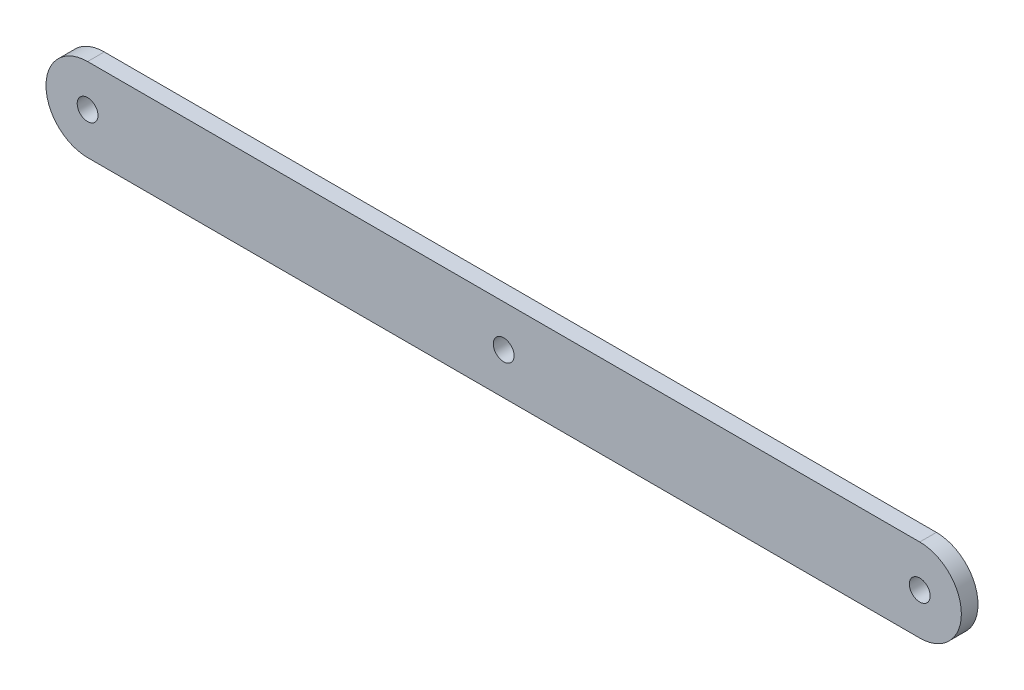
from build123d import *

# Parameters (mm, degrees)
SKETCH1_R           = 12.5
BOSS_EXTRUDE1_DEPTH = 20


with BuildPart() as part:
    # Sketch1 → Boss-Extrude1 (new body)
    with BuildSketch(Plane.XY):
        with BuildLine():
            Line((-500, 50), (500, 50))
            ThreePointArc((500, 50), (550, 0), (500, -50))
            Line((500, -50), (-500, -50))
            ThreePointArc((-500, -50), (-550, 0), (-500, 50))
        make_face()
        with Locations((-500, 0)):
            Circle(SKETCH1_R, mode=Mode.SUBTRACT)
        with Locations((500, 0)):
            Circle(SKETCH1_R, mode=Mode.SUBTRACT)
        Circle(SKETCH1_R, mode=Mode.SUBTRACT)
    extrude(amount=BOSS_EXTRUDE1_DEPTH)


solid = part.part
